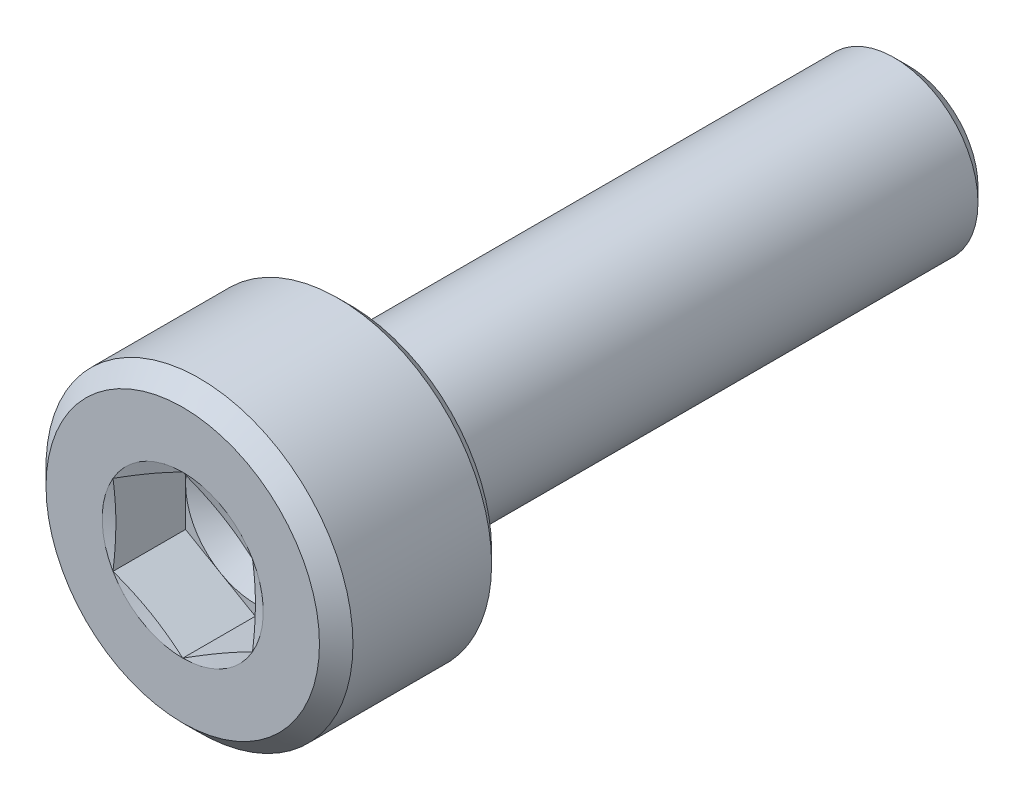
from build123d import *

# Parameters (mm, degrees)
CUT_EXTRUDE1_DEPTH = 1.3


with BuildPart() as part:
    # Sketch1 → Revolve1 (revolve)
    with BuildSketch(Plane(origin=(0, 0, 0), x_dir=(0, 0, -1), z_dir=(1, 0, 0))):
        with BuildLine():
            Line((0, 0), (0, 2.45))
            Line((0, 2.45), (0.3, 2.75))
            Line((0.3, 2.75), (2.785, 2.75))
            Line((2.785, 2.75), (3, 2.535))
            Line((3, 2.535), (3, 1.8))
            ThreePointArc((3, 1.8), (3.015193643, 1.74701055), (3.056157637, 1.710123155))
            Line((3.056157637, 1.710123155), (3.466157637, 1.510123155))
            ThreePointArc((3.466157637, 1.510123155), (3.48750205, 1.50256365), (3.51, 1.5))
            Line((3.51, 1.5), (12.75, 1.5))
            Line((12.75, 1.5), (13, 1.25))
            Line((13, 1.25), (13, 0))
            Line((13, 0), (0, 0))
        make_face()
    revolve(axis=Axis((0, 0, 0), (0, 0, -1)))

    # Sketch2 → Cut-Extrude1 (cut)
    with BuildSketch(Plane.XY):
        Polygon((0, 1.443375673), (-1.25, 0.721687836), (-1.25, -0.721687836), (0, -1.443375673), (1.25, -0.721687836), (1.25, 0.721687836), align=None)
    extrude(amount=-CUT_EXTRUDE1_DEPTH, mode=Mode.SUBTRACT)

    # Sketch3 → Cut-Revolve2 (revolve, cut)
    with BuildSketch(Plane(origin=(0, 0, 0), x_dir=(0, 0, -1), z_dir=(1, 0, 0))):
        Polygon((1.3, 0), (1.3, 1.25), (2.021687836, 0), align=None)
    revolve(axis=Axis((0, 0, -1.3), (0, 0, -1)), mode=Mode.SUBTRACT)

    # Sketch4 → Cut-Revolve3 (revolve, cut)
    with BuildSketch(Plane(origin=(0, 0, 0), x_dir=(0, 0, -1), z_dir=(1, 0, 0))):
        Polygon((0, 1.443375673), (0, 1.25), (0.051814855, 1.25), align=None)
    revolve(axis=Axis((0, 0, 0), (0, 0, -1)), mode=Mode.SUBTRACT)


solid = part.part
